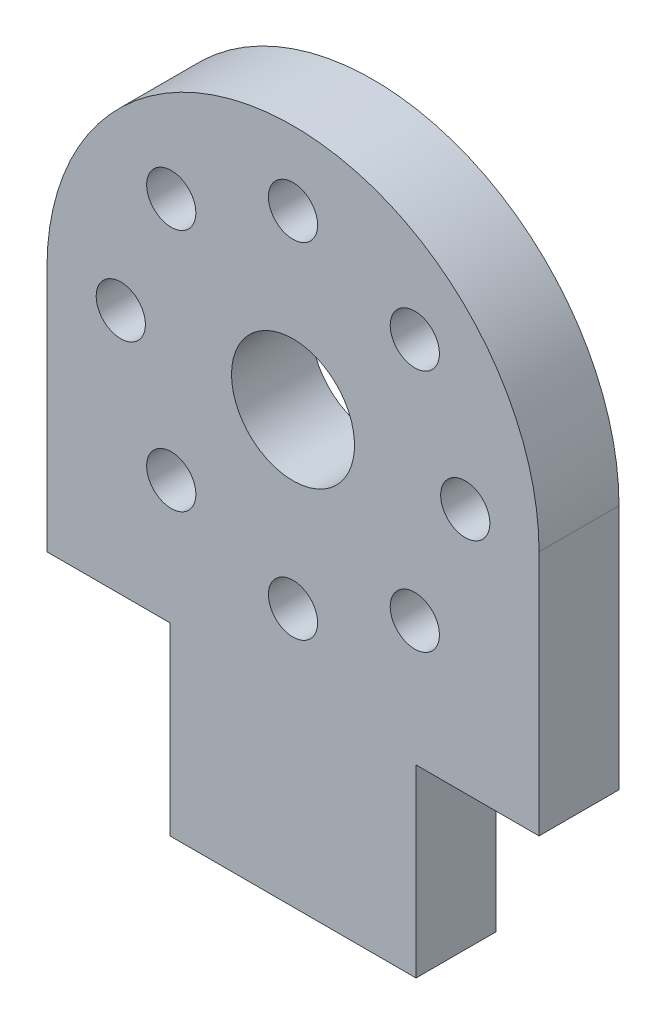
from build123d import *
from build123d.topology import SkipClean

# Parameters (mm, degrees)
ESQUISSE1_R           = 15
ESQUISSE1_R_2         = 5
ESQUISSE1_R_3         = 2
EXTRUSION1_DEPTH      = 6.5
ESQUISSE2_R           = 9
ESQUISSE2_R_2         = 1.5
EXTRUSION2_DEPTH      = 30
ESQUISSE3_R           = 15
EXTRUSION3_DEPTH      = 27
EXTRUSION4_DEPTH      = 104.717163478
EXTRUSION4_DEPTH_BACK = 104.717163478
EXTRUSION5_DEPTH      = 104.717163478
ESQUISSE6_W           = 10
ESQUISSE6_H           = 15
EXTRUSION6_DEPTH      = 59.883359279


with BuildPart() as part:
    # Esquisse1 → Extrusion1 (new body)
    with BuildSketch(Plane.XY):
        with BuildLine():
            Line((20, -20), (20, -75))
            ThreePointArc((20, -75), (0, -95), (-20, -75))
            Line((-20, -75), (-20, -20))
            ThreePointArc((-20, -20), (0, 0), (20, -20))
        make_face()
        with Locations(Location((0, -75, 0), (0, 0, 180))):
            Circle(ESQUISSE1_R, mode=Mode.SUBTRACT)
        with Locations(Location((0, -20, 0), (0, 0, 180))):
            Circle(ESQUISSE1_R_2, mode=Mode.SUBTRACT)
        with Locations(Location((-14, -20, 0), (0, 0, 180))):
            Circle(ESQUISSE1_R_3, mode=Mode.SUBTRACT)
        with Locations(Location((-9.899494937, -10.100505063, 0), (0, 0, 180))):
            Circle(ESQUISSE1_R_3, mode=Mode.SUBTRACT)
        with Locations(Location((0, -6, 0), (0, 0, 180))):
            Circle(ESQUISSE1_R_3, mode=Mode.SUBTRACT)
        with Locations(Location((9.899494937, -10.100505063, 0), (0, 0, 180))):
            Circle(ESQUISSE1_R_3, mode=Mode.SUBTRACT)
        with Locations(Location((14, -20, 0), (0, 0, 180))):
            Circle(ESQUISSE1_R_3, mode=Mode.SUBTRACT)
        with Locations(Location((9.899494937, -29.899494937, 0), (0, 0, 180))):
            Circle(ESQUISSE1_R_3, mode=Mode.SUBTRACT)
        with Locations(Location((0, -34, 0), (0, 0, 180))):
            Circle(ESQUISSE1_R_3, mode=Mode.SUBTRACT)
        with Locations(Location((-9.899494937, -29.899494937, 0), (0, 0, 180))):
            Circle(ESQUISSE1_R_3, mode=Mode.SUBTRACT)
    extrude(amount=EXTRUSION1_DEPTH)

    # Esquisse2 → Extrusion2 (add)
    with SkipClean():  # the faces are left unmerged after this step: merging them gives an invalid solid
        with BuildSketch(Plane.XY.offset(6.5)):
            with BuildLine():
                Line((12, -59), (-12, -59))
                ThreePointArc((-12, -59), (0, -95), (12, -59))
            make_face()
            with Locations((0, -75)):
                Circle(ESQUISSE2_R, mode=Mode.SUBTRACT)
            with Locations((0, -62)):
                Circle(ESQUISSE2_R_2, mode=Mode.SUBTRACT)
            with Locations((0, -88)):
                Circle(ESQUISSE2_R_2, mode=Mode.SUBTRACT)
            with Locations((-13, -75)):
                Circle(ESQUISSE2_R_2, mode=Mode.SUBTRACT)
            with Locations((13, -75)):
                Circle(ESQUISSE2_R_2, mode=Mode.SUBTRACT)
        extrude(amount=EXTRUSION2_DEPTH)

    # Esquisse3 → Extrusion3 (cut)
    with SkipClean():  # the faces are left unmerged after this step: merging them gives an invalid solid
        with BuildSketch(Plane(origin=(0, 0, 6.5), x_dir=(-1, 0, 0), z_dir=(0, 0, -1))):
            with Locations((0, -75)):
                Circle(ESQUISSE3_R)
        extrude(amount=-EXTRUSION3_DEPTH, mode=Mode.SUBTRACT)

    # Esquisse4 → Extrusion4 (cut, two sides: drawn at the far end of the back side and taken through both)
    with SkipClean():  # the faces are left unmerged after this step: merging them gives an invalid solid
        with BuildSketch(Plane(origin=(0, 0, 0), x_dir=(0, 0, -1), z_dir=(1, 0, 0)).offset(-EXTRUSION4_DEPTH_BACK)):
            Polygon((-36.5, -95), (-30, -95), (-36.5, -90), align=None)
        extrude(amount=EXTRUSION4_DEPTH + EXTRUSION4_DEPTH_BACK, mode=Mode.SUBTRACT)

    # Esquisse5 → Extrusion5 (cut, through all)
    with BuildSketch(Plane.XY.offset(36.5)):
        with BuildLine():
            Line((20, -55), (-20, -55))
            Line((-20, -55), (-20, -75))
            ThreePointArc((-20, -75), (0, -95), (20, -75))
            Line((20, -75), (20, -55))
        make_face()
    extrude(amount=-EXTRUSION5_DEPTH, mode=Mode.SUBTRACT)

    # Esquisse6 → Extrusion6 (cut, through all)
    with BuildSketch(Plane.XY.offset(6.5)):
        with Locations((-15, -47.5)):
            Rectangle(ESQUISSE6_W, ESQUISSE6_H)
        with Locations((15, -47.5)):
            Rectangle(ESQUISSE6_W, ESQUISSE6_H)
    extrude(amount=-EXTRUSION6_DEPTH, mode=Mode.SUBTRACT)


solid = part.part
